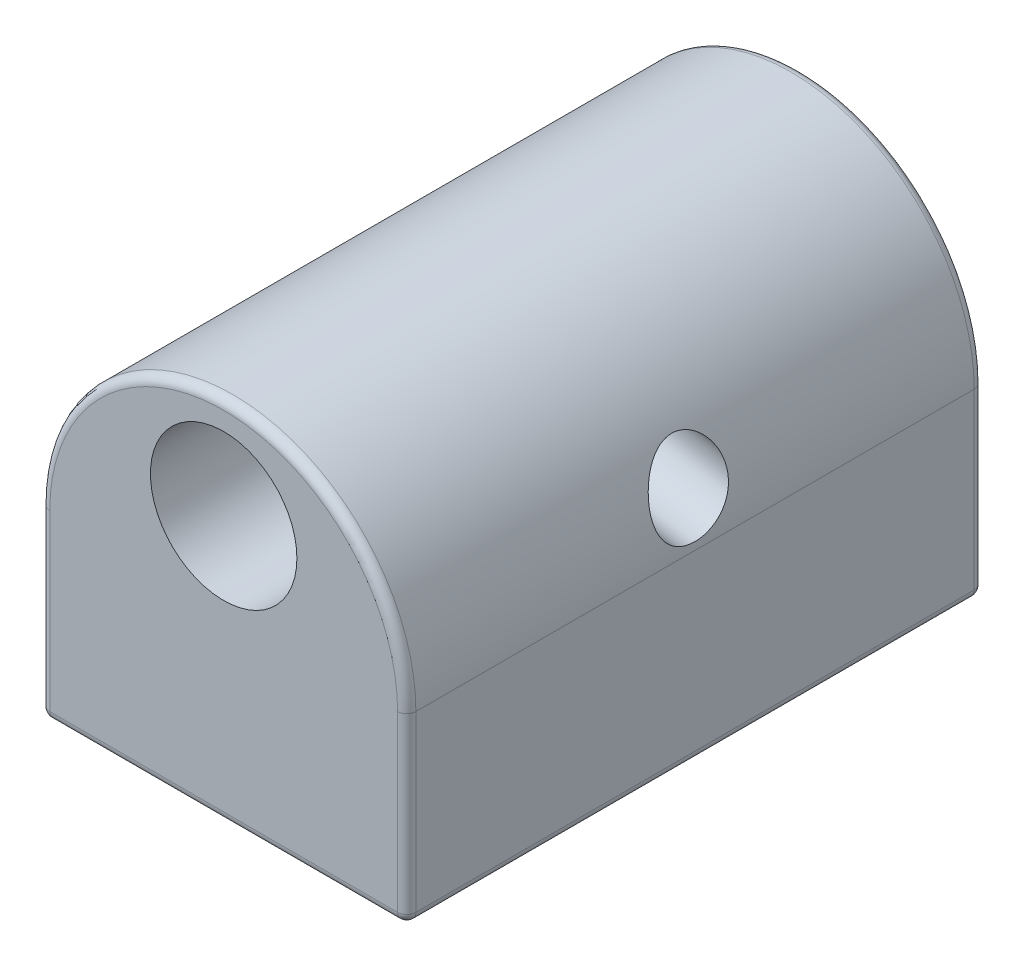
from build123d import *

# Parameters (mm, degrees)
ESQUISSE1_R            = 4
BOSS_EXTRU_1_DEPTH     = 15.75
TROU_TARAUD_M101_D     = 8.5
TROU_TARAUD_M101_DEPTH = 15
TROU_TARAUD_M101_TIP   = 2.553657631
TROU_TARAUD_M51_D      = 4.2
TROU_TARAUD_M51_DEPTH  = 10
TROU_TARAUD_M51_TIP    = 1.2618073
CONG_1_R               = 0.5


with BuildPart() as part:
    # Esquisse1 → Boss.-Extru.1 (new body, symmetric)
    with BuildSketch(Plane.XY):
        with BuildLine():
            Line((-10, 0), (-10, -10))
            Line((-10, -10), (10, -10))
            Line((10, -10), (10, 0))
            ThreePointArc((10, 0), (0, 10), (-10, 0))
        make_face()
        with Locations((0, 4.5)):
            Circle(ESQUISSE1_R, mode=Mode.SUBTRACT)
    extrude(amount=BOSS_EXTRU_1_DEPTH, both=True)

    # Trou taraudé M101
    with Locations(Plane(origin=(0, -10, 0), x_dir=(-1, 0, 0), z_dir=(0, -1, 0))):
        with Locations((0, 0)):
            Hole(TROU_TARAUD_M101_D / 2, depth=TROU_TARAUD_M101_DEPTH)
            with Locations((0, 0, -(TROU_TARAUD_M101_DEPTH + TROU_TARAUD_M101_TIP / 2))):  # 118° drill point
                Cone(0, TROU_TARAUD_M101_D / 2, TROU_TARAUD_M101_TIP, mode=Mode.SUBTRACT)

    # Trou taraudé M51
    with Locations(Plane(origin=(9.698463104, -1.710100717, 0), x_dir=(0, 0, -1), z_dir=(0.984807753, -0.173648178, 0))):
        with Locations((0, 4.236481777)):
            Hole(TROU_TARAUD_M51_D / 2, depth=TROU_TARAUD_M51_DEPTH)
            with Locations((0, 0, -(TROU_TARAUD_M51_DEPTH + TROU_TARAUD_M51_TIP / 2))):  # 118° drill point
                Cone(0, TROU_TARAUD_M51_D / 2, TROU_TARAUD_M51_TIP, mode=Mode.SUBTRACT)

    # Congé1
    cong_1_edges = [part.edges().sort_by_distance(p)[0] for p in [
        (0, -10, 15.75),
        (10, -5, 15.75),
        (0, 10, 15.75),
        (10, -5, -15.75),
        (0, -10, -15.75),
        (-10, -5, -15.75),
        (0, 10, -15.75),
        (-10, -5, 15.75),
        (10, -10, 0),
        (-10, -10, 0),
    ]]
    fillet(cong_1_edges, radius=CONG_1_R)


solid = part.part
